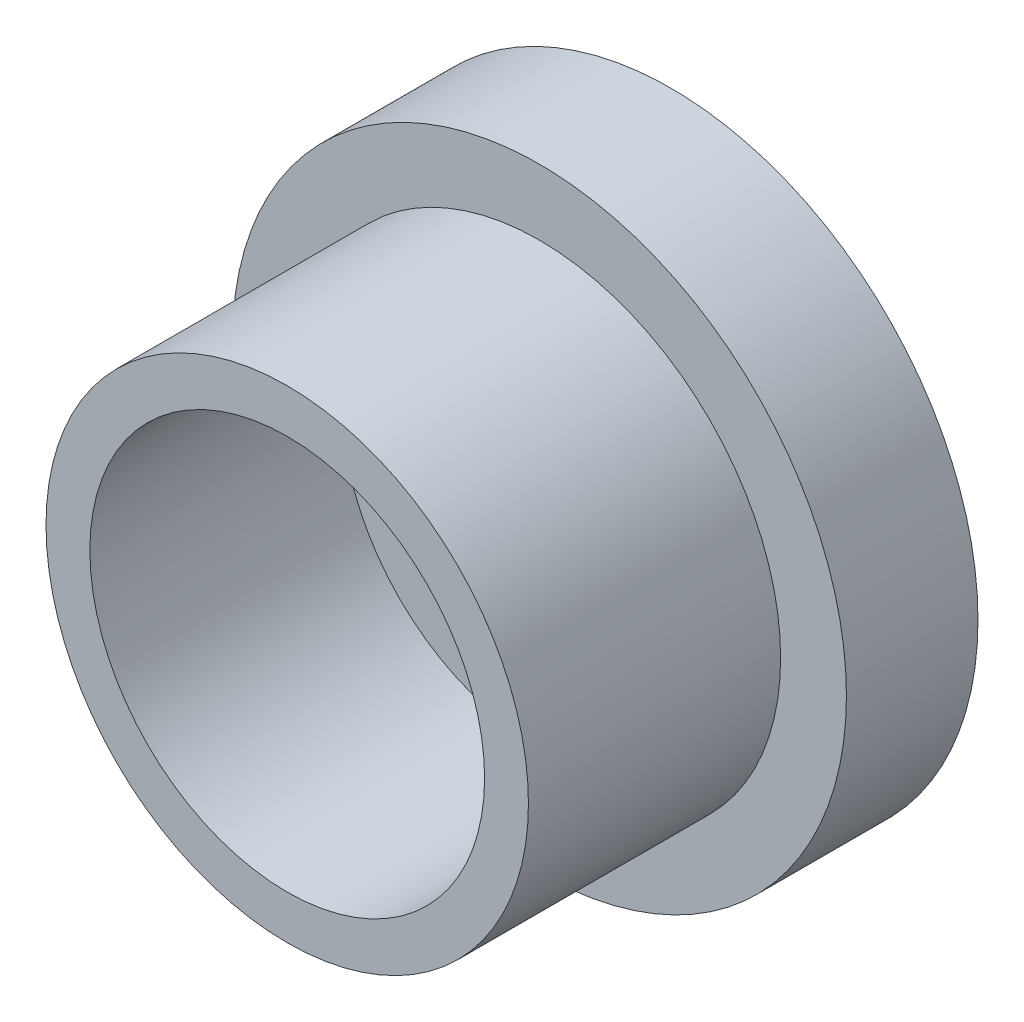
from build123d import *

# Parameters (mm, degrees)
SKETCH_1_R      = 2.2
SKETCH_1_R_2    = 1.8
EXTRUDE_2_DEPTH = 3.5
SKETCH_1_6_R    = 2.8
EXTRUDE_3_DEPTH = 1.2


with BuildPart() as part:
    # Эскиз1 → Бобышка-Вытянуть2 (new body)
    with BuildSketch(Plane.XY):
        Circle(SKETCH_1_R)
        Circle(SKETCH_1_R_2, mode=Mode.SUBTRACT)
    extrude(amount=EXTRUDE_2_DEPTH)

    # Эскиз1<6> → Бобышка-Вытянуть3 (add)
    with BuildSketch(Plane.XY):
        Circle(SKETCH_1_6_R)
    extrude(amount=EXTRUDE_3_DEPTH)


solid = part.part
